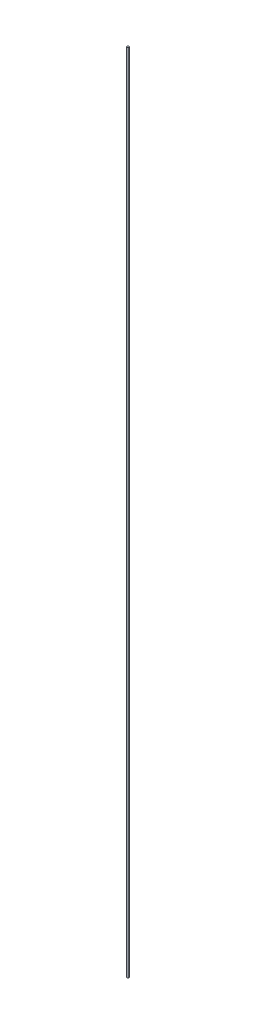
from build123d import *

# Parameters (mm, degrees)
SKETCH2_R           = 1.016
BOSS_EXTRUDE1_DEPTH = 914.4


with BuildPart() as part:
    # Sketch2 → Boss-Extrude1 (new body)
    with BuildSketch(Plane(origin=(0, 0, 0), x_dir=(1, 0, 0), z_dir=(0, 1, 0))):
        Circle(SKETCH2_R)
    extrude(amount=BOSS_EXTRUDE1_DEPTH)


solid = part.part
